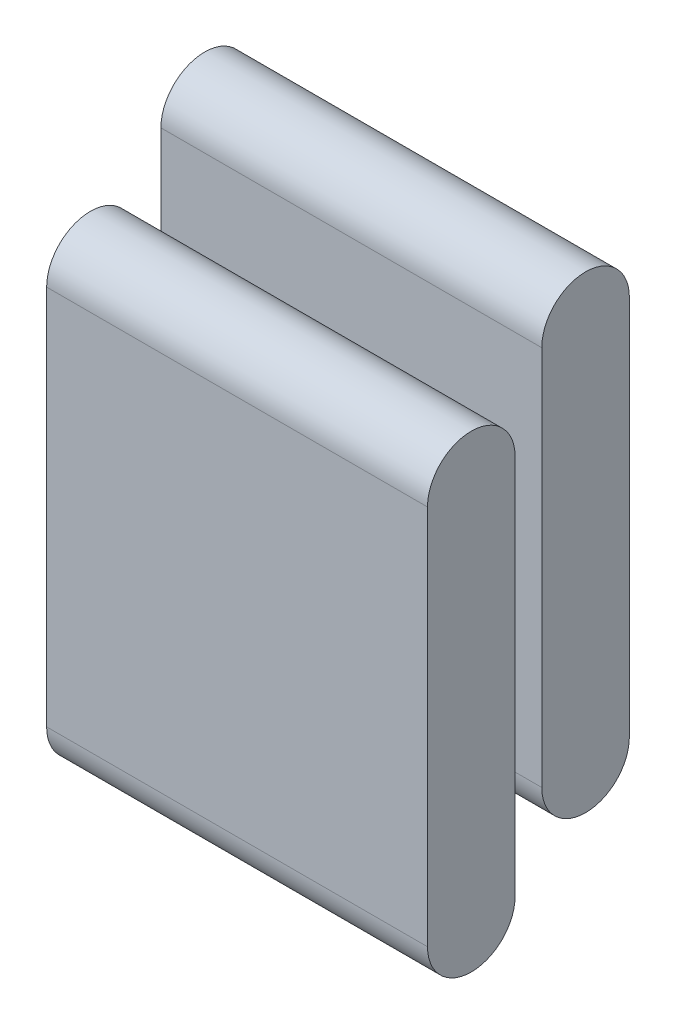
from build123d import *

# Parameters (mm, degrees)
EXTRUDE_1_DEPTH   = 10
EXTRUDE_1_2_DEPTH = 10


with BuildPart() as part:
    # 草图1 → 凸台-拉伸1 (new body)
    with BuildSketch(Plane(origin=(0, 0, 0), x_dir=(0, 0, -1), z_dir=(1, 0, 0))):
        with BuildLine():
            Line((-8.85, 16.820508076), (-8.85, 6.820508076))
            ThreePointArc((-8.85, 6.820508076), (-10, 5.670508076), (-11.15, 6.820508076))
            Line((-11.15, 6.820508076), (-11.15, 16.820508076))
            ThreePointArc((-11.15, 16.820508076), (-10, 17.970508076), (-8.85, 16.820508076))
        make_face()
    extrude(amount=EXTRUDE_1_DEPTH)


with BuildPart() as body_2:
    # 草图1 → Extrude 1 2 (new body)
    with BuildSketch(Plane(origin=(0, 0, 0), x_dir=(0, 0, -1), z_dir=(1, 0, 0))):
        with BuildLine():
            Line((-11.85, 14.698684154), (-11.85, 4.698684154))
            ThreePointArc((-11.85, 4.698684154), (-13, 3.548684154), (-14.15, 4.698684154))
            Line((-14.15, 4.698684154), (-14.15, 14.698684154))
            ThreePointArc((-14.15, 14.698684154), (-13, 15.848684154), (-11.85, 14.698684154))
        make_face()
    extrude(amount=EXTRUDE_1_2_DEPTH)


solid = Compound([part.part, body_2.part])
